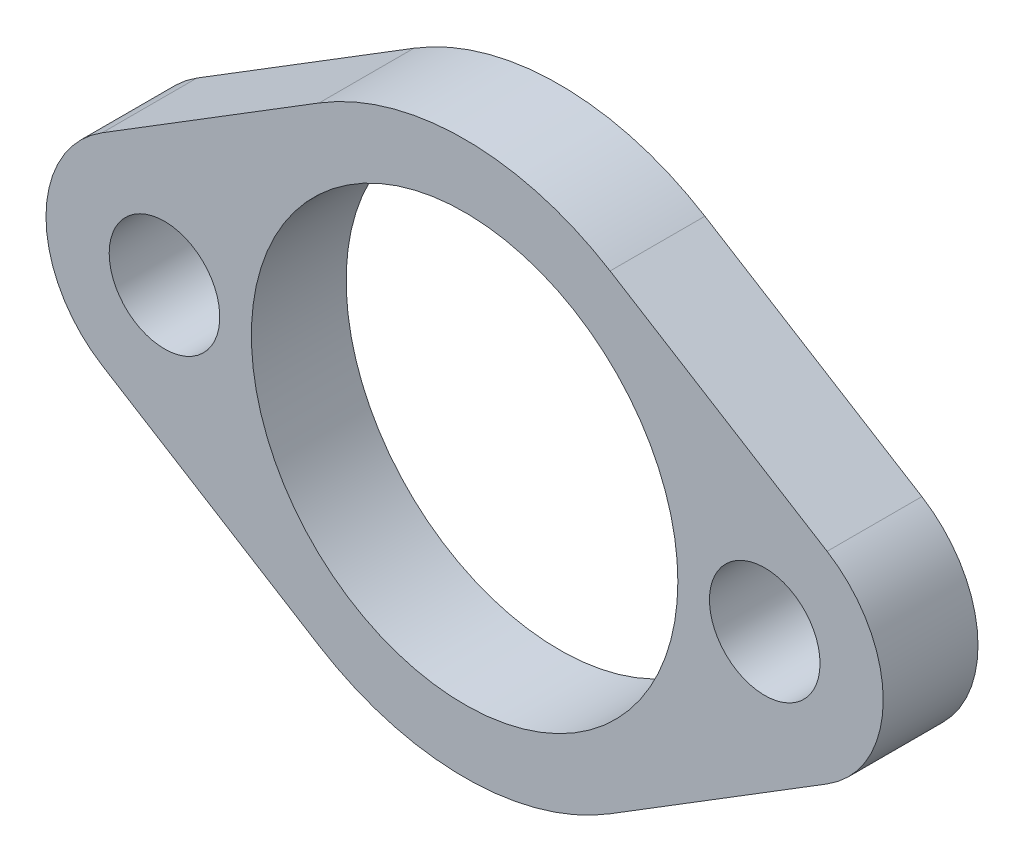
from build123d import *

# Parameters (mm, degrees)
SZKIC1_R                    = 6.75
SZKIC1_R_2                  = 1.75
DODANIE_WYCI_GNI_CIE1_DEPTH = 3


with BuildPart() as part:
    # Szkic1 → Dodanie-wyciągnięcie1 (new body)
    with BuildSketch(Plane.XY):
        with BuildLine():
            Line((4.605263158, 7.440030326), (11.473684211, 3.188584425))
            ThreePointArc((11.473684211, 3.188584425), (13.25, 0), (11.473684211, -3.188584425))
            Line((11.473684211, -3.188584425), (4.605263158, -7.440030326))
            ThreePointArc((4.605263158, -7.440030326), (0, -8.75), (-4.605263158, -7.440030326))
            Line((-4.605263158, -7.440030326), (-11.473684211, -3.188584425))
            ThreePointArc((-11.473684211, -3.188584425), (-13.25, 0), (-11.473684211, 3.188584425))
            Line((-11.473684211, 3.188584425), (-4.605263158, 7.440030326))
            ThreePointArc((-4.605263158, 7.440030326), (0, 8.75), (4.605263158, 7.440030326))
        make_face()
        Circle(SZKIC1_R, mode=Mode.SUBTRACT)
        with Locations((9.5, 0)):
            Circle(SZKIC1_R_2, mode=Mode.SUBTRACT)
        with Locations((-9.5, 0)):
            Circle(SZKIC1_R_2, mode=Mode.SUBTRACT)
    extrude(amount=DODANIE_WYCI_GNI_CIE1_DEPTH)


solid = part.part
